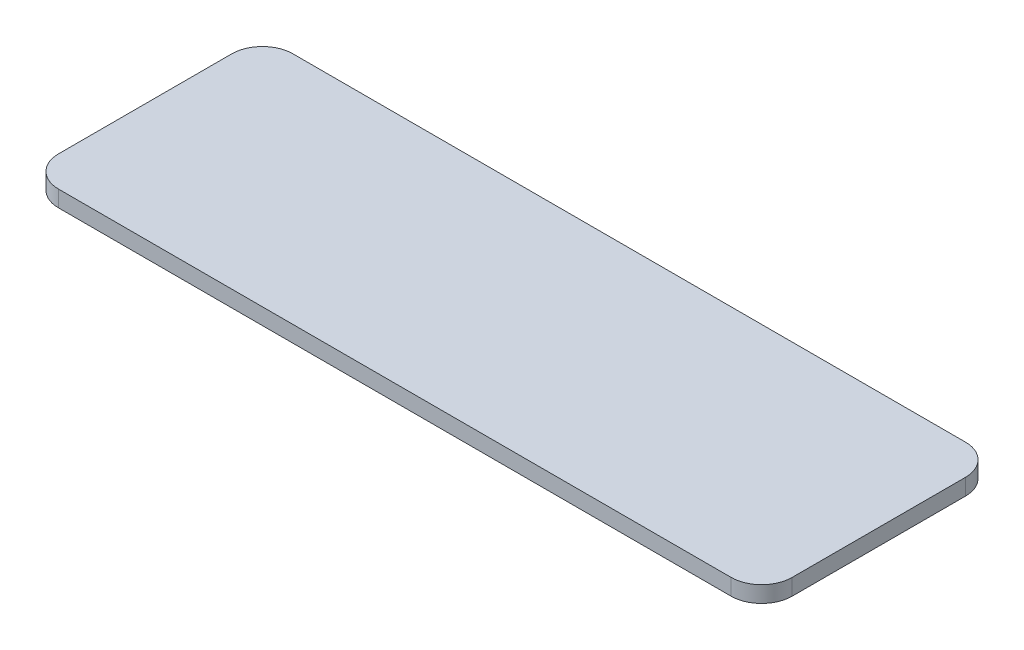
from build123d import *

# Parameters (mm, degrees)
BOSS_EXTRUDE1_DEPTH = 1.6


with BuildPart() as part:
    # Sketch1 → Boss-Extrude1 (new body)
    with BuildSketch(Plane(origin=(0, 0, 0), x_dir=(1, 0, 0), z_dir=(0, 1, 0))):
        with BuildLine():
            Line((3, 0), (69, 0))
            ThreePointArc((69, 0), (71.121320344, 0.878679656), (72, 3))
            Line((72, 3), (72, 20))
            ThreePointArc((72, 20), (71.121320344, 22.121320344), (69, 23))
            Line((69, 23), (3, 23))
            ThreePointArc((3, 23), (0.878679656, 22.121320344), (0, 20))
            Line((0, 20), (0, 3))
            ThreePointArc((0, 3), (0.878679656, 0.878679656), (3, 0))
        make_face()
    extrude(amount=BOSS_EXTRUDE1_DEPTH)


solid = part.part
